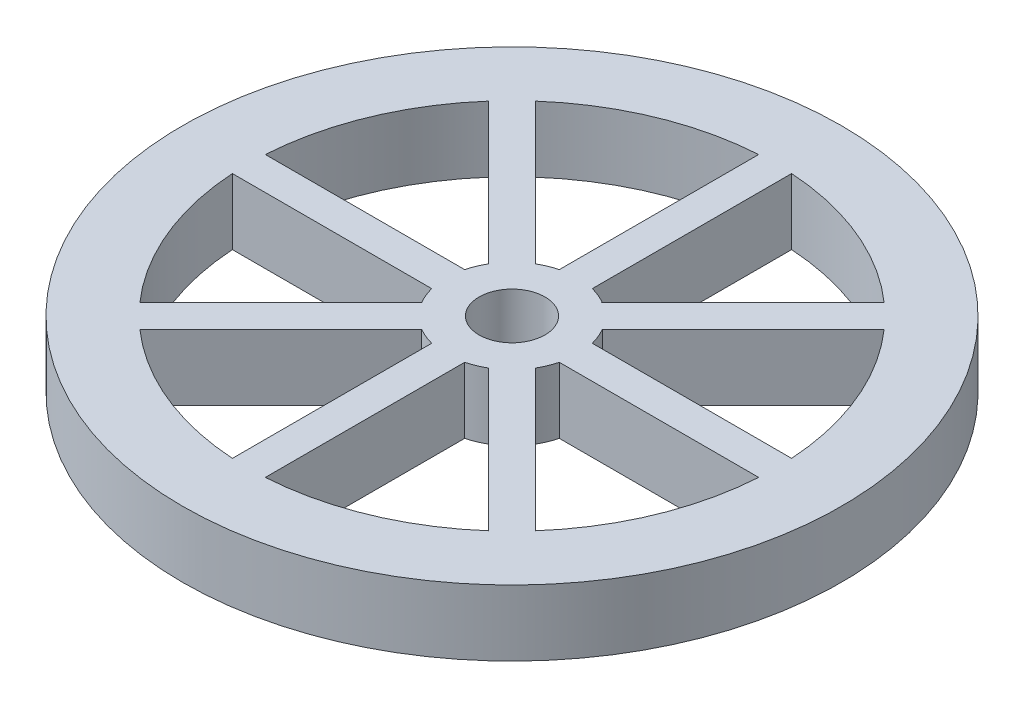
from build123d import *

# Parameters (mm, degrees)
SKETCH1_R           = 31.75
SKETCH1_R_2         = 3.175
BOSS_EXTRUDE1_DEPTH = 6.35


with BuildPart() as part:
    # Sketch1 → Boss-Extrude1 (new body)
    with BuildSketch(Plane(origin=(0, 0, 0), x_dir=(1, 0, 0), z_dir=(0, 1, 0))):
        Circle(SKETCH1_R)
        with BuildLine():
            Line((-1.5875, -6.148361062), (-1.5875, -25.350342083))
            ThreePointArc((-1.5875, -25.350342083), (-9.720159182, -23.466540126), (-16.802866778, -19.047930808))
            Line((-16.802866778, -19.047930808), (-3.225015785, -5.470079815))
            ThreePointArc((-3.225015785, -5.470079815), (-2.430039796, -5.866635031), (-1.5875, -6.148361062))
        make_face(mode=Mode.SUBTRACT)
        with BuildLine():
            Line((-5.470079815, -3.225015785), (-19.047930808, -16.802866778))
            ThreePointArc((-19.047930808, -16.802866778), (-23.466540126, -9.720159182), (-25.350342083, -1.5875))
            Line((-25.350342083, -1.5875), (-6.148361062, -1.5875))
            ThreePointArc((-6.148361062, -1.5875), (-5.866635031, -2.430039796), (-5.470079815, -3.225015785))
        make_face(mode=Mode.SUBTRACT)
        with BuildLine():
            Line((3.225015785, -5.470079815), (16.802866778, -19.047930808))
            ThreePointArc((16.802866778, -19.047930808), (9.720159182, -23.466540126), (1.5875, -25.350342083))
            Line((1.5875, -25.350342083), (1.5875, -6.148361062))
            ThreePointArc((1.5875, -6.148361062), (2.430039796, -5.866635031), (3.225015785, -5.470079815))
        make_face(mode=Mode.SUBTRACT)
        with BuildLine():
            Line((6.148361062, -1.5875), (25.350342083, -1.5875))
            ThreePointArc((25.350342083, -1.5875), (23.466540126, -9.720159182), (19.047930808, -16.802866778))
            Line((19.047930808, -16.802866778), (5.470079815, -3.225015785))
            ThreePointArc((5.470079815, -3.225015785), (5.866635031, -2.430039796), (6.148361062, -1.5875))
        make_face(mode=Mode.SUBTRACT)
        with BuildLine():
            Line((-6.148361062, 1.5875), (-25.350342083, 1.5875))
            ThreePointArc((-25.350342083, 1.5875), (-23.466540126, 9.720159182), (-19.047930808, 16.802866778))
            Line((-19.047930808, 16.802866778), (-5.470079815, 3.225015785))
            ThreePointArc((-5.470079815, 3.225015785), (-5.866635031, 2.430039796), (-6.148361062, 1.5875))
        make_face(mode=Mode.SUBTRACT)
        with BuildLine():
            ThreePointArc((-16.802866778, 19.047930808), (-9.720159182, 23.466540126), (-1.5875, 25.350342083))
            Line((-1.5875, 25.350342083), (-1.5875, 6.148361062))
            ThreePointArc((-1.5875, 6.148361062), (-2.430039796, 5.866635031), (-3.225015785, 5.470079815))
            Line((-3.225015785, 5.470079815), (-16.802866778, 19.047930808))
        make_face(mode=Mode.SUBTRACT)
        Circle(SKETCH1_R_2, mode=Mode.SUBTRACT)
        with BuildLine():
            Line((5.470079815, 3.225015785), (19.047930808, 16.802866778))
            ThreePointArc((19.047930808, 16.802866778), (23.466540126, 9.720159182), (25.350342083, 1.5875))
            Line((25.350342083, 1.5875), (6.148361062, 1.5875))
            ThreePointArc((6.148361062, 1.5875), (5.866635031, 2.430039796), (5.470079815, 3.225015785))
        make_face(mode=Mode.SUBTRACT)
        with BuildLine():
            Line((3.225015785, 5.470079815), (3.175, 5.42006403))
            Line((3.175, 5.42006403), (3.175, 5.499261314))
            ThreePointArc((3.175, 5.499261314), (2.403265317, 5.877653938), (1.5875, 6.148361062))
            Line((1.5875, 6.148361062), (1.5875, 25.350342083))
            ThreePointArc((1.5875, 25.350342083), (9.720159182, 23.466540126), (16.802866778, 19.047930808))
            Line((16.802866778, 19.047930808), (3.225015785, 5.470079815))
        make_face(mode=Mode.SUBTRACT)
    extrude(amount=BOSS_EXTRUDE1_DEPTH)


solid = part.part
